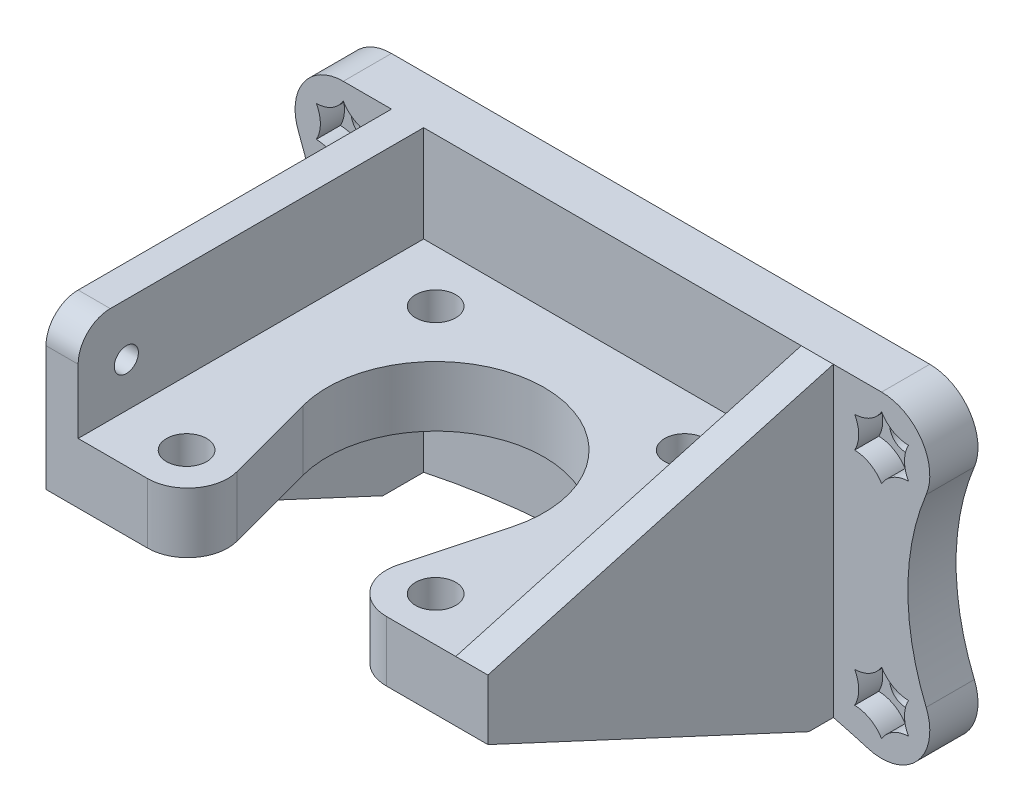
from build123d import *

# Parameters (mm, degrees)
BOSS_EXTRUDE1_DEPTH  = 49
SKETCH2_R            = 2.5
CUT_EXTRUDE1_DEPTH   = 8.5
SKETCH4_W            = 79
SKETCH4_H            = 39.5
BOSS_EXTRUDE2_DEPTH  = 6
BOSS_EXTRUDE3_DEPTH  = 4
SKETCH5_R            = 2
CUT_EXTRUDE3_DEPTH   = 10
BOSS_EXTRUDE4_DEPTH  = 4
SKETCH8_R            = 1.5
CUT_EXTRUDE4_DEPTH   = 8
FILLET1_R            = 6
FILLET2_R            = 5
CUT_EXTRUDE5_DEPTH   = 3
CUT_EXTRUDE6_DEPTH   = 50
FILLET3_R            = 4
CUT_EXTRUDE7_DEPTH   = 3
LPATTERN1_COUNT      = 2
LPATTERN1_PITCH      = 67
LPATTERN1_COUNT_DIR2 = 2
LPATTERN1_PITCH_DIR2 = 27.5


with BuildPart() as part:
    # Sketch1 → Boss-Extrude1 (new body)
    with BuildSketch(Plane.XY):
        Polygon((4, 7.5), (4, 19.5), (0, 19.5), (0, 0), (55, 0), (55, 7.5), align=None)
    extrude(amount=BOSS_EXTRUDE1_DEPTH)

    # Sketch2 → Cut-Extrude1 (cut, through all)
    with BuildSketch(Plane(origin=(0, 7.5, 0), x_dir=(1, 0, 0), z_dir=(0, 1, 0))):
        with Locations(Location((12, -12.5, 0), (0, 0, 270))):  # turned: the seam where the file's is
            Circle(SKETCH2_R)
        with Locations(Location((43, -12.5, 0), (0, 0, 270))):  # turned: the seam where the file's is
            Circle(SKETCH2_R)
        with Locations(Location((12, -43.5, 0), (0, 0, 270))):  # turned: the seam where the file's is
            Circle(SKETCH2_R)
        with Locations(Location((43, -43.5, 0), (0, 0, 270))):  # turned: the seam where the file's is
            Circle(SKETCH2_R)
        with BuildLine():
            Line((14.460001345, -31.494057109), (19.150704606, -49))
            Line((19.150704606, -49), (35.849295394, -49))
            Line((35.849295394, -49), (40.539998655, -31.494057109))
            ThreePointArc((40.539998655, -31.494057109), (27.5, -14.5), (14.460001345, -31.494057109))
        make_face()
    extrude(amount=-CUT_EXTRUDE1_DEPTH, mode=Mode.SUBTRACT)

    # Sketch4 → Boss-Extrude2 (add)
    with BuildSketch(Plane(origin=(0, 0, 0), x_dir=(-1, 0, 0), z_dir=(0, 0, -1))):
        with Locations((-27.5, -0.25)):
            Rectangle(SKETCH4_W, SKETCH4_H)
    extrude(amount=-BOSS_EXTRUDE2_DEPTH)

    # Sketch6 → Boss-Extrude3 (add)
    with BuildSketch(Plane.ZY):
        Polygon((6, -20), (49, 0), (6, 0), align=None)
    extrude(amount=-BOSS_EXTRUDE3_DEPTH)

    # Sketch5 → Cut-Extrude3 (cut)
    with BuildSketch(Plane(origin=(0, 0, 0), x_dir=(-1, 0, 0), z_dir=(0, 0, -1))):
        with Locations((-61, 13.5)):
            Circle(SKETCH5_R)
        with Locations((-61, -14)):
            Circle(SKETCH5_R)
        with Locations((6, 13.5)):
            Circle(SKETCH5_R)
        with Locations((6, -14)):
            Circle(SKETCH5_R)
    extrude(amount=-CUT_EXTRUDE3_DEPTH, mode=Mode.SUBTRACT)

    # Sketch7 → Boss-Extrude4 (add)
    with BuildSketch(Plane(origin=(55, 0, 0), x_dir=(0, 0, -1), z_dir=(1, 0, 0))):
        Polygon((-49, 7.5), (-6, 19.5), (0, 19.5), (0, -20), (-6, -20), (-49, 0), align=None)
    extrude(amount=-BOSS_EXTRUDE4_DEPTH)

    # Sketch8 → Cut-Extrude4 (cut)
    with BuildSketch(Plane.ZY):
        with Locations(Location((43, 13, 0), (0, 0, 270))):  # turned: the seam where the file's is
            Circle(SKETCH8_R)
        with Locations(Location((43, 3.5, 0), (0, 0, 270))):  # turned: the seam where the file's is
            Circle(SKETCH8_R)
    extrude(amount=-CUT_EXTRUDE4_DEPTH, mode=Mode.SUBTRACT)

    # Fillet1
    fillet1_edges = [part.edges().sort_by_distance(p)[0] for p in [
        (67, 19.5, 3),
        (-12, 19.5, 3),
        (-12, -20, 3),
        (67, -20, 3),
    ]]
    fillet(fillet1_edges, radius=FILLET1_R)

    # Fillet2
    fillet2_edges = [part.edges().sort_by_distance(p)[0] for p in [
        (35.849295394, 3.75, 49),
        (19.150704606, 3.75, 49),
    ]]
    fillet(fillet2_edges, radius=FILLET2_R)

    # Sketch9 → Cut-Extrude5 (cut)
    with BuildSketch(Plane.XY.offset(6)):
        Polygon((-6, 16.790896534), (-8.85, 15.145448267), (-8.85, 11.854551733), (-6, 10.209103466), (-3.15, 11.854551733), (-3.15, 15.145448267), align=None)
        Polygon((-6, -10.709103466), (-8.85, -12.354551733), (-8.85, -15.645448267), (-6, -17.290896534), (-3.15, -15.645448267), (-3.15, -12.354551733), align=None)
        Polygon((61, -10.709103466), (58.15, -12.354551733), (58.15, -15.645448267), (61, -17.290896534), (63.85, -15.645448267), (63.85, -12.354551733), align=None)
        Polygon((61, 10.209103466), (63.85, 11.854551733), (63.85, 15.145448267), (61, 16.790896534), (58.15, 15.145448267), (58.15, 11.854551733), align=None)
    extrude(amount=-CUT_EXTRUDE5_DEPTH, mode=Mode.SUBTRACT)

    # Sketch10 → Cut-Extrude6 (cut, through all)
    with BuildSketch(Plane(origin=(0, 0, 0), x_dir=(-1, 0, 0), z_dir=(0, 0, -1))):
        with BuildLine():
            Line((-61, 19.5), (-61, 26.194717678))
            Line((-61, 26.194717678), (-93.21372943, 26.194717678))
            Line((-93.21372943, 26.194717678), (-93.21372943, -32.483465835))
            Line((-93.21372943, -32.483465835), (20.656804912, -32.483465835))
            Line((20.656804912, -32.483465835), (20.656804912, 27.240467483))
            Line((20.656804912, 27.240467483), (6, 27.240467483))
            Line((6, 27.240467483), (6, 19.5))
            ThreePointArc((6, 19.5), (10.987484336, 16.835416016), (11.545111711, 11.208333333))
            ThreePointArc((11.545111711, 11.208333333), (9.270670267, -0.25), (11.545111711, -11.708333333))
            ThreePointArc((11.545111711, -11.708333333), (10.460015748, -18.013509627), (4.303797468, -19.755249514))
            ThreePointArc((4.303797468, -19.755249514), (-27.5, -15.166177907), (-59.303797468, -19.755249514))
            ThreePointArc((-59.303797468, -19.755249514), (-65.460015748, -18.013509627), (-66.545111711, -11.708333333))
            ThreePointArc((-66.545111711, -11.708333333), (-64.270670267, -0.25), (-66.545111711, 11.208333333))
            ThreePointArc((-66.545111711, 11.208333333), (-65.987484336, 16.835416016), (-61, 19.5))
        make_face()
    extrude(amount=-CUT_EXTRUDE6_DEPTH, mode=Mode.SUBTRACT)

    # Fillet3
    fillet3_edges = [part.edges().sort_by_distance(p)[0] for p in [
        (2, 19.5, 49),
    ]]
    fillet(fillet3_edges, radius=FILLET3_R)

    # Sketch11 → Cut-Extrude7 (cut)
    with BuildSketch(Plane.XY.offset(6)):
        with BuildLine():
            ThreePointArc((-9.35, 15.434123402), (-8.85, 13.5), (-9.35, 11.565876598))
            ThreePointArc((-9.35, 11.565876598), (-7.425, 11.031827599), (-6, 9.631753196))
            ThreePointArc((-6, 9.631753196), (-4.575, 11.031827599), (-2.65, 11.565876598))
            ThreePointArc((-2.65, 11.565876598), (-3.15, 13.5), (-2.65, 15.434123402))
            ThreePointArc((-2.65, 15.434123402), (-4.575, 15.968172401), (-6, 17.368246804))
            ThreePointArc((-6, 17.368246804), (-7.425, 15.968172401), (-9.35, 15.434123402))
        make_face()
    cut_extrude7 = extrude(amount=-CUT_EXTRUDE7_DEPTH, mode=Mode.SUBTRACT)

    # LPattern1: Cut-Extrude7 2 × 2
    with Locations(*[(i * LPATTERN1_PITCH, -j * LPATTERN1_PITCH_DIR2, 0) for i in range(LPATTERN1_COUNT) for j in range(LPATTERN1_COUNT_DIR2) if (i, j) != (0, 0)]):
        add(cut_extrude7, mode=Mode.SUBTRACT)


solid = part.part
